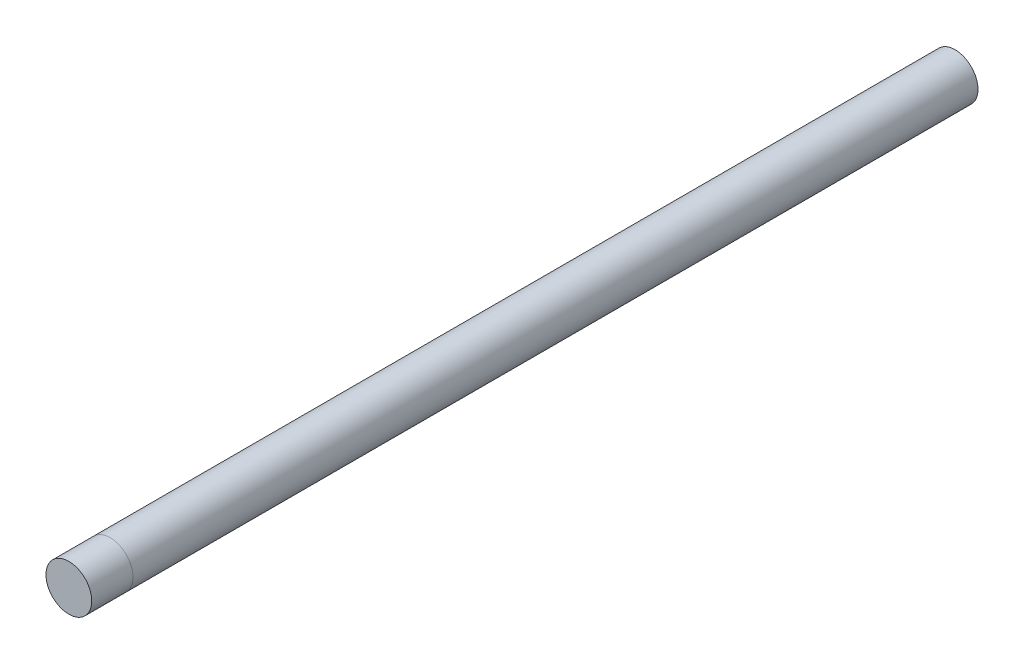
from build123d import *

# Parameters (mm, degrees)
SKETCH1_R           = 5
BOSS_EXTRUDE1_DEPTH = 184.5
SKETCH2_R           = 5
BOSS_EXTRUDE2_DEPTH = 9


with BuildPart() as part:
    # Sketch1 → Boss-Extrude1 (new body)
    with BuildSketch(Plane.XY):
        Circle(SKETCH1_R)
    extrude(amount=BOSS_EXTRUDE1_DEPTH)


with BuildPart() as body_2:
    # Sketch2 → Boss-Extrude2 (new body)
    with BuildSketch(Plane.XY.offset(184.5)):
        Circle(SKETCH2_R)
    extrude(amount=BOSS_EXTRUDE2_DEPTH)


solid = Compound([part.part, body_2.part])
